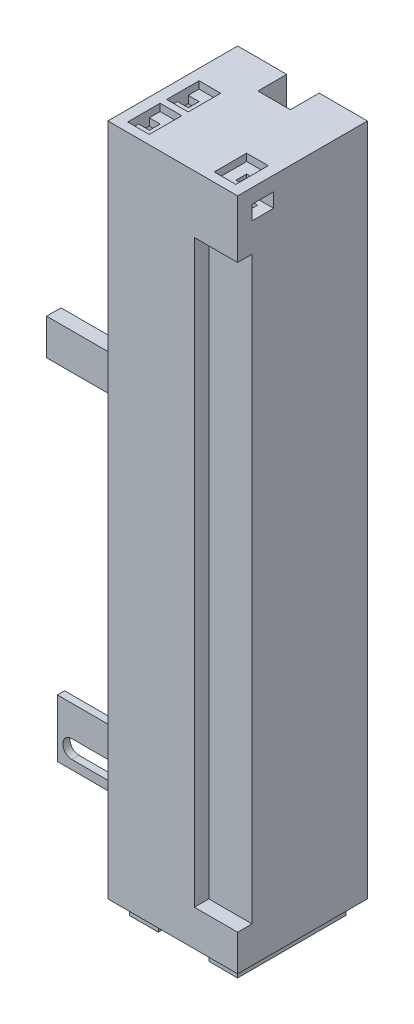
from build123d import *

# Parameters (mm, degrees)
SKETCH1_W           = 36
SKETCH1_H           = 36
BOSS_EXTRUDE1_DEPTH = 186.9
BOSS_EXTRUDE2_DEPTH = 4
SKETCH3_R           = 2
CUT_EXTRUDE1_DEPTH  = 5
SKETCH4_W           = 9
SKETCH4_H           = 186.9
CUT_EXTRUDE2_DEPTH  = 8
SKETCH5_W           = 6
SKETCH5_H           = 4
CUT_EXTRUDE3_DEPTH  = 9
SKETCH6_W           = 3
SKETCH6_H           = 3
CUT_EXTRUDE4_DEPTH  = 10
SKETCH7_W           = 2
SKETCH7_H           = 16
BOSS_EXTRUDE3_DEPTH = 40
CUT_EXTRUDE5_REACH  = 12
SKETCH9_W           = 4
SKETCH9_H           = 10
BOSS_EXTRUDE4_DEPTH = 45
CHAMFER1_SIZE       = 20
CUT_EXTRUDE6_DEPTH  = 27
SKETCH11_W          = 6
SKETCH11_H          = 4
SKETCH11_H_2        = 6
CUT_EXTRUDE7_DEPTH  = 9
SKETCH12_W          = 3
SKETCH12_H          = 3
CUT_EXTRUDE8_DEPTH  = 10
SKETCH13_W          = 12
SKETCH13_H          = 160.9
CUT_EXTRUDE9_DEPTH  = 4
SKETCH14_W          = 6
SKETCH14_H          = 9
CUT_EXTRUDE10_DEPTH = 2


with BuildPart() as part:
    # Sketch1 → Boss-Extrude1 (new body)
    with BuildSketch(Plane(origin=(0, 0, 0), x_dir=(1, 0, 0), z_dir=(0, 1, 0))):
        with Locations((18, 18)):
            Rectangle(SKETCH1_W, SKETCH1_H)
    extrude(amount=BOSS_EXTRUDE1_DEPTH)

    # Sketch2 → Boss-Extrude2 (add)
    with BuildSketch(Plane.XZ):
        Polygon((3, -3), (7, -3), (11, -3), (11, -11), (7, -11), (7, -25), (11, -25), (11, -33), (7, -33), (3, -33), align=None)
        Polygon((29, -3), (33, -3), (33, -33), (29, -33), (25, -33), (25, -25), (29, -25), (29, -11), (25, -11), (25, -3), align=None)
    extrude(amount=BOSS_EXTRUDE2_DEPTH)

    # Sketch3 → Cut-Extrude1 (cut)
    with BuildSketch(Plane.XZ):
        with Locations((18, -18)):
            Circle(SKETCH3_R)
    extrude(amount=-CUT_EXTRUDE1_DEPTH, mode=Mode.SUBTRACT)

    # Sketch4 → Cut-Extrude2 (cut)
    with BuildSketch(Plane.XY.offset(-36)):
        with Locations((18.12, 93.45)):
            Rectangle(SKETCH4_W, SKETCH4_H)
    extrude(amount=CUT_EXTRUDE2_DEPTH, mode=Mode.SUBTRACT)

    # Sketch5 → Cut-Extrude3 (cut)
    with BuildSketch(Plane(origin=(36, 0, 0), x_dir=(0, 0, -1), z_dir=(1, 0, 0))):
        with Locations((7, 180.9)):
            Rectangle(SKETCH5_W, SKETCH5_H)
    extrude(amount=-CUT_EXTRUDE3_DEPTH, mode=Mode.SUBTRACT)

    # Sketch6 → Cut-Extrude4 (cut)
    with BuildSketch(Plane(origin=(0, 186.9, 0), x_dir=(1, 0, 0), z_dir=(0, 1, 0))):
        with Locations((31.5, 7)):
            Rectangle(SKETCH6_W, SKETCH6_H)
    extrude(amount=-CUT_EXTRUDE4_DEPTH, mode=Mode.SUBTRACT)

    # Sketch7 → Boss-Extrude3 (add)
    with BuildSketch(Plane.ZY):
        with Locations((-27, 8)):
            Rectangle(SKETCH7_W, SKETCH7_H)
    extrude(amount=BOSS_EXTRUDE3_DEPTH)

    # Sketch8 → Cut-Extrude5 (cut, up to next)
    with BuildSketch(Plane.XY.offset(-26), mode=Mode.PRIVATE) as cut_extrude5_sk1:
        with BuildLine():
            Line((-36, 7.5), (-12, 7.5))
            ThreePointArc((-12, 7.5), (-9.5, 5), (-12, 2.5))
            Line((-12, 2.5), (-36, 2.5))
            ThreePointArc((-36, 2.5), (-38.5, 5), (-36, 7.5))
        make_face()
    cut_extrude5_tool1 = extrude(cut_extrude5_sk1.sketch, amount=-CUT_EXTRUDE5_REACH, mode=Mode.PRIVATE) & part.part
    add(cut_extrude5_tool1.solids().sort_by_distance((-24, 5, -26))[0], mode=Mode.SUBTRACT)

    # Sketch9 → Boss-Extrude4 (add)
    with BuildSketch(Plane.ZY):
        with Locations((-30, 98.5)):
            Rectangle(SKETCH9_W, SKETCH9_H)
    extrude(amount=BOSS_EXTRUDE4_DEPTH)

    # Chamfer1
    chamfer1_edges = [part.edges().sort_by_distance(p)[0] for p in [
        (0, 16, -27),
        (0, 93.5, -30),
    ]]
    chamfer(chamfer1_edges, length=CHAMFER1_SIZE)

    # Sketch10 → Cut-Extrude6 (cut)
    with BuildSketch(Plane.XY.offset(-26)):
        Polygon((-17.171572875, 93.5), (-2, 78.328427125), (-2, 93.5), align=None)
        Polygon((-17.171572875, 16), (-2, 31.171572875), (-2, 16), align=None)
    extrude(amount=-CUT_EXTRUDE6_DEPTH, mode=Mode.SUBTRACT)

    # Sketch11 → Cut-Extrude7 (cut)
    with BuildSketch(Plane.ZY):
        with Locations((-7, 180.9)):
            Rectangle(SKETCH11_W, SKETCH11_H)
        with Locations((-17.8, 180.9)):
            Rectangle(SKETCH11_W, SKETCH11_H)
        with Locations((-13, 169.9)):
            Rectangle(SKETCH11_W, SKETCH11_H_2)
    extrude(amount=-CUT_EXTRUDE7_DEPTH, mode=Mode.SUBTRACT)

    # Sketch12 → Cut-Extrude8 (cut)
    with BuildSketch(Plane(origin=(0, 186.9, 0), x_dir=(1, 0, 0), z_dir=(0, 1, 0))):
        with Locations((4.5, 7)):
            Rectangle(SKETCH12_W, SKETCH12_H)
        with Locations((4.5, 17.8)):
            Rectangle(SKETCH12_W, SKETCH12_H)
    extrude(amount=-CUT_EXTRUDE8_DEPTH, mode=Mode.SUBTRACT)

    # Sketch13 → Cut-Extrude9 (cut)
    with BuildSketch(Plane.XY):
        with Locations((30, 90.45)):
            Rectangle(SKETCH13_W, SKETCH13_H)
    extrude(amount=-CUT_EXTRUDE9_DEPTH, mode=Mode.SUBTRACT)

    # Sketch14 → Cut-Extrude10 (cut)
    with BuildSketch(Plane(origin=(0, 186.9, 0), x_dir=(1, 0, 0), z_dir=(0, 1, 0))):
        with Locations((30, 7)):
            Rectangle(SKETCH14_W, SKETCH14_H)
        with Locations((6, 17.8)):
            Rectangle(SKETCH14_W, SKETCH14_H)
        with Locations((6, 7)):
            Rectangle(SKETCH14_W, SKETCH14_H)
    extrude(amount=-CUT_EXTRUDE10_DEPTH, mode=Mode.SUBTRACT)


solid = part.part
